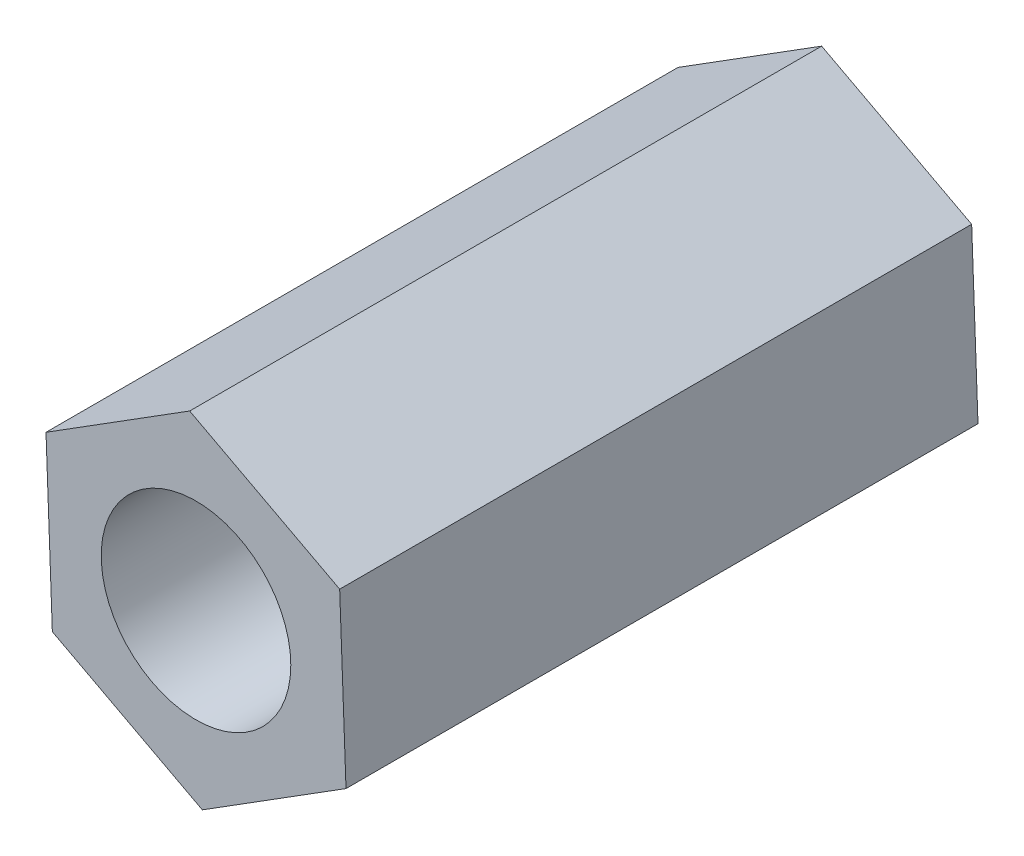
from build123d import *

# Parameters (mm, degrees)
SKETCH_1_R      = 1.5
EXTRUDE_1_DEPTH = 10


with BuildPart() as part:
    # 草图1 → 凸台-拉伸1 (new body)
    with BuildSketch(Plane.XY):
        Polygon((2.273206082, 1.428297627), (-0.100338988, 2.682803028), (-2.37354507, 1.254505402), (-2.273206082, -1.428297627), (0.100338988, -2.682803028), (2.37354507, -1.254505402), align=None)
        Circle(SKETCH_1_R, mode=Mode.SUBTRACT)
    extrude(amount=EXTRUDE_1_DEPTH)


solid = part.part
